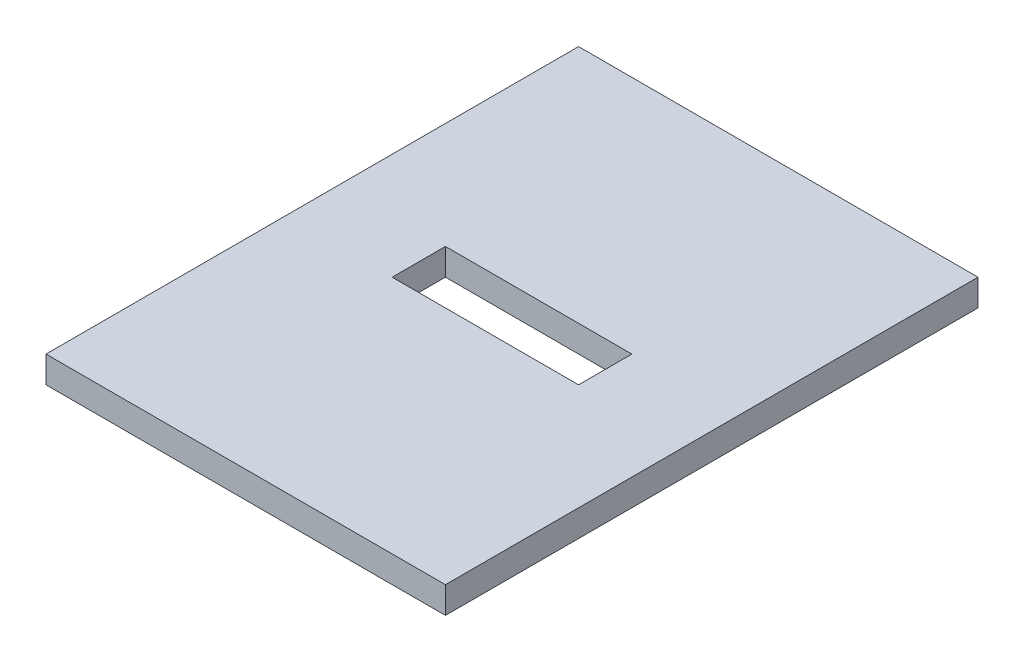
from build123d import *

# Parameters (mm, degrees)
SKIZZE1_W                            = 150
SKIZZE1_H                            = 200
AUFSATZ_LINEAR_AUSTRAGEN1_DEPTH      = 10
SKIZZE2_W                            = 70
SKIZZE2_H                            = 20
SCHNITT_LINEAR_AUSTRAGEN2_DEPTH      = 1
SCHNITT_LINEAR_AUSTRAGEN2_DEPTH_BACK = 11


with BuildPart() as part:
    # Skizze1 → Aufsatz-Linear austragen1 (new body)
    with BuildSketch(Plane(origin=(0, 0, 0), x_dir=(1, 0, 0), z_dir=(0, 1, 0))):
        with Locations((25, 50)):
            Rectangle(SKIZZE1_W, SKIZZE1_H)
    extrude(amount=AUFSATZ_LINEAR_AUSTRAGEN1_DEPTH)

    # Skizze2 → Schnitt-Linear austragen2 (cut, two sides)
    with BuildSketch(Plane.XZ) as schnitt_linear_austragen2_sk:
        with Locations((25, -50)):
            Rectangle(SKIZZE2_W, SKIZZE2_H)
    extrude(amount=SCHNITT_LINEAR_AUSTRAGEN2_DEPTH, mode=Mode.SUBTRACT)
    extrude(schnitt_linear_austragen2_sk.sketch, amount=-SCHNITT_LINEAR_AUSTRAGEN2_DEPTH_BACK, mode=Mode.SUBTRACT)


solid = part.part
